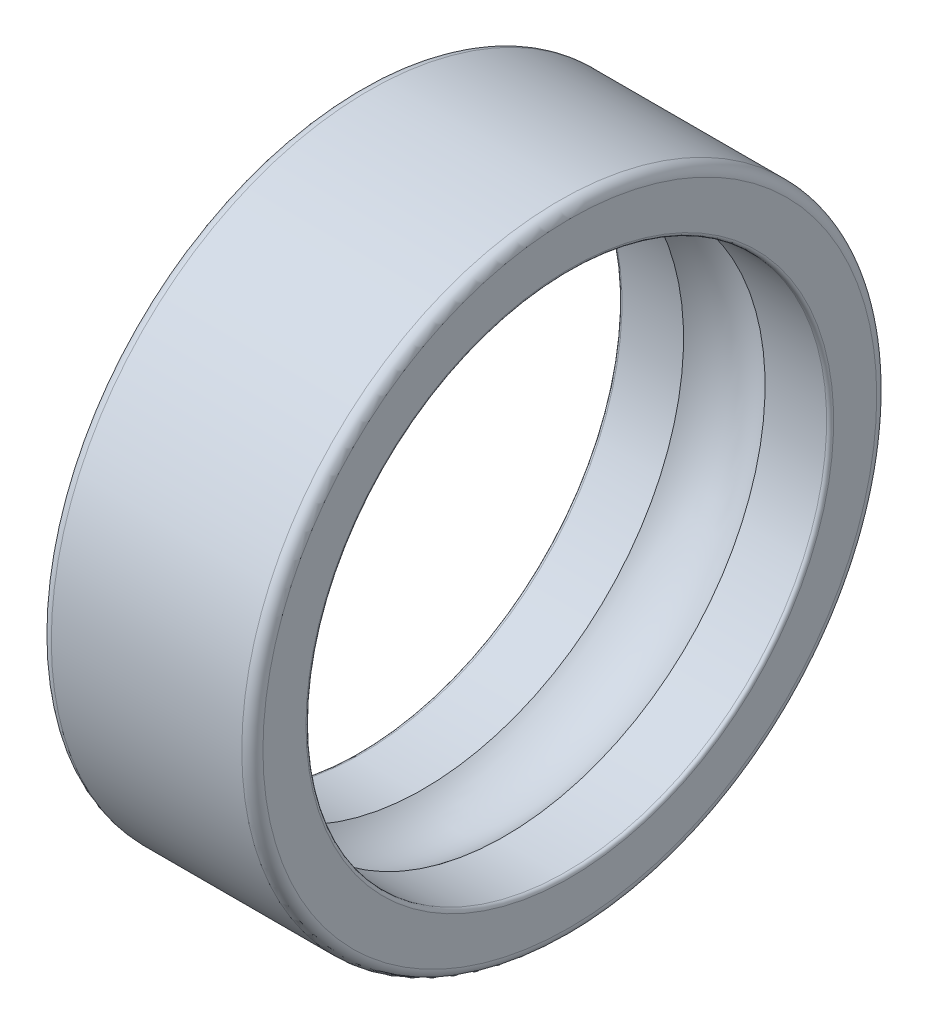
from build123d import *


with BuildPart() as part:
    # Sketch1 → Revolve1 (revolve)
    with BuildSketch(Plane.XY):
        with BuildLine():
            Line((0.016666667, 1.23), (0.307386397, 1.23))
            ThreePointArc((0.307386397, 1.23), (0.5, 1.3), (0.692613603, 1.23))
            Line((0.692613603, 1.23), (0.983333333, 1.23))
            ThreePointArc((0.983333333, 1.23), (0.995118446, 1.234881554), (1, 1.246666667))
            Line((1, 1.246666667), (1, 1.45))
            ThreePointArc((1, 1.45), (0.985355339, 1.485355339), (0.95, 1.5))
            Line((0.95, 1.5), (0.05, 1.5))
            ThreePointArc((0.05, 1.5), (0.014644661, 1.485355339), (0, 1.45))
            Line((0, 1.45), (0, 1.246666667))
            ThreePointArc((0, 1.246666667), (0.004881554, 1.234881554), (0.016666667, 1.23))
        make_face()
    revolve(axis=Axis((1, 0, 0), (-1, 0, 0)))


solid = part.part
